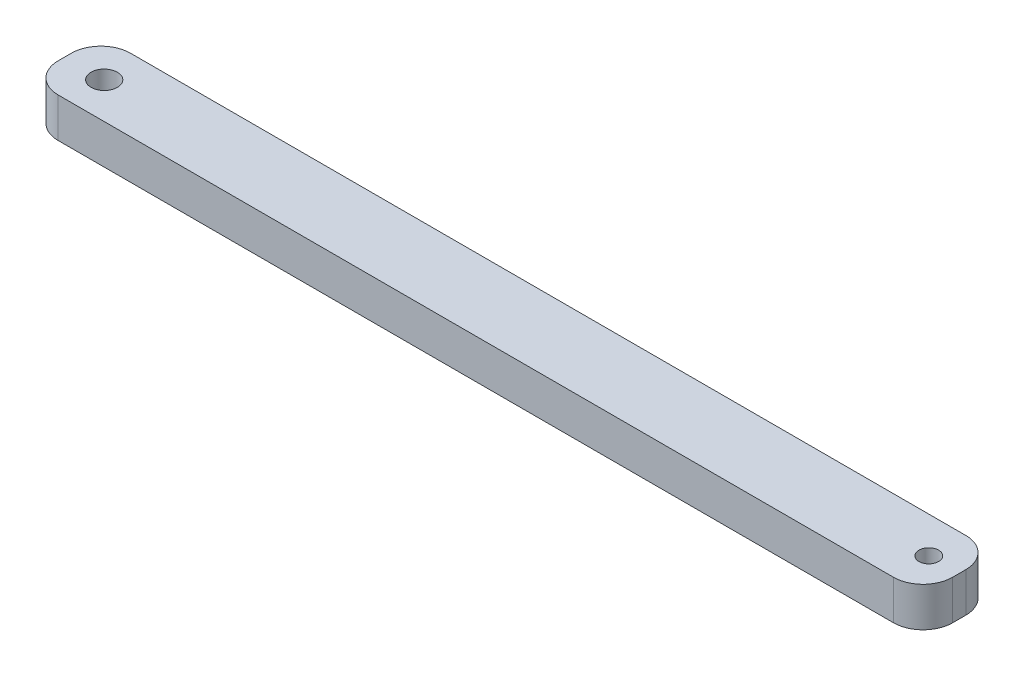
from build123d import *

# Parameters (mm, degrees)
CROQUIS1_W              = 68
CROQUIS1_H              = 5.5
CROQUIS1_R              = 0.75
CROQUIS1_R_2            = 1
SALIENTE_EXTRUIR1_DEPTH = 3
REDONDEO1_R             = 2.25


with BuildPart() as part:
    # Croquis1 → Saliente-Extruir1 (new body)
    with BuildSketch(Plane(origin=(0, 0, 0), x_dir=(1, 0, 0), z_dir=(0, 1, 0))):
        with Locations((4.363095238, 10.94047619)):
            Rectangle(CROQUIS1_W, CROQUIS1_H)
        with Locations((36.048095238, 10.94047619)):
            Circle(CROQUIS1_R, mode=Mode.SUBTRACT)
        with Locations((-26.636904762, 10.94047619)):
            Circle(CROQUIS1_R_2, mode=Mode.SUBTRACT)
    extrude(amount=SALIENTE_EXTRUIR1_DEPTH)

    # Redondeo1
    redondeo1_edges = [part.edges().sort_by_distance(p)[0] for p in [
        (-29.636904762, 1.5, -13.69047619),
        (38.363095238, 1.5, -13.69047619),
        (38.363095238, 1.5, -8.19047619),
        (-29.636904762, 1.5, -8.19047619),
    ]]
    fillet(redondeo1_edges, radius=REDONDEO1_R)


solid = part.part
